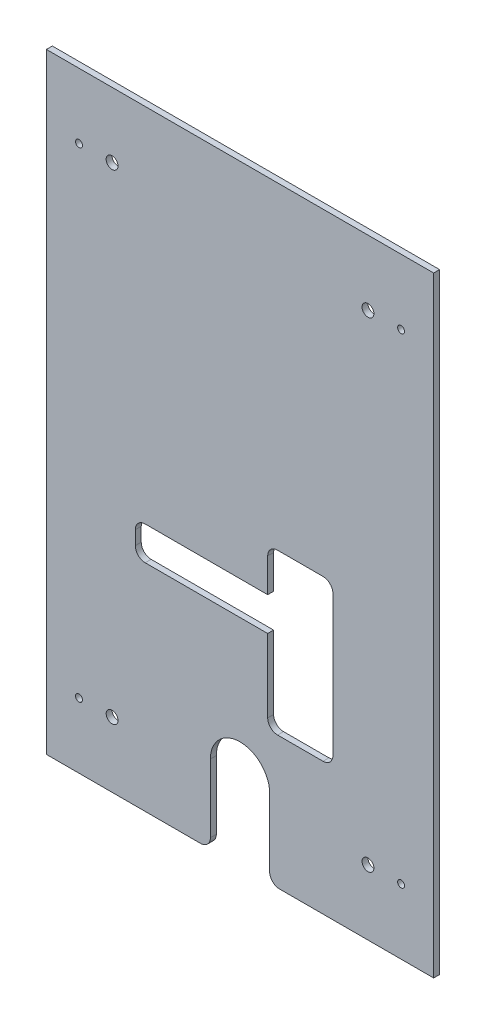
from build123d import *

# Parameters (mm, degrees)
ESQUISSE1_W             = 196
ESQUISSE1_H             = 309
ESQUISSE1_R             = 1.75
ESQUISSE1_R_2           = 3
BOSS_EXTRU_1_DEPTH      = 3
ENL_V_MAT_EXTRU_1_REACH = 5
CONG_1_R                = 5
ENL_V_MAT_EXTRU_2_DEPTH = 4
CONG_2_R                = 5


with BuildPart() as part:
    # Esquisse1 → Boss.-Extru.1 (new body)
    with BuildSketch(Plane.XY):
        Rectangle(ESQUISSE1_W, ESQUISSE1_H)
        with Locations((-81.5, 121.5)):
            Circle(ESQUISSE1_R, mode=Mode.SUBTRACT)
        with Locations((81.5, 121.5)):
            Circle(ESQUISSE1_R, mode=Mode.SUBTRACT)
        with Locations((81.5, -121.5)):
            Circle(ESQUISSE1_R, mode=Mode.SUBTRACT)
        with Locations((-81.5, -121.5)):
            Circle(ESQUISSE1_R, mode=Mode.SUBTRACT)
        with Locations((64.75, 121.5)):
            Circle(ESQUISSE1_R_2, mode=Mode.SUBTRACT)
        with Locations((-64.75, 121.5)):
            Circle(ESQUISSE1_R_2, mode=Mode.SUBTRACT)
        with Locations((-64.75, -121.5)):
            Circle(ESQUISSE1_R_2, mode=Mode.SUBTRACT)
        with Locations((64.75, -121.5)):
            Circle(ESQUISSE1_R_2, mode=Mode.SUBTRACT)
    extrude(amount=BOSS_EXTRU_1_DEPTH)

    # Esquisse2 → Enlèv. mat.-Extru.1 (cut, up to next)
    with BuildSketch(Plane.XY.offset(3), mode=Mode.PRIVATE) as enl_v_mat_extru_1_sk1:
        with BuildLine():
            Line((-15, -154.5), (-15, -115))
            ThreePointArc((-15, -115), (0, -100), (15, -115))
            Line((15, -115), (15, -154.5))
            ThreePointArc((15, -154.5), (0, -169.5), (-15, -154.5))
        make_face()
    enl_v_mat_extru_1_tool1 = extrude(enl_v_mat_extru_1_sk1.sketch, amount=-ENL_V_MAT_EXTRU_1_REACH, mode=Mode.PRIVATE) & part.part
    add(enl_v_mat_extru_1_tool1.solids().sort_by_distance((0, -134.75, 3))[0], mode=Mode.SUBTRACT)

    # Congé1
    cong_1_edges = [part.edges().sort_by_distance(p)[0] for p in [
        (-15, -154.5, 1.5),
        (15, -154.5, 1.5),
    ]]
    fillet(cong_1_edges, radius=CONG_1_R)

    # Esquisse3 → Enlèv. mat.-Extru.2 (cut, through all)
    with BuildSketch(Plane.XY.offset(3)):
        Polygon((-53, -28.5), (14, -28.5), (14, -6.5), (47, -6.5), (47, -87.5), (14, -87.5), (14, -45.5), (-53, -45.5), align=None)
    extrude(amount=-ENL_V_MAT_EXTRU_2_DEPTH, mode=Mode.SUBTRACT)

    # Congé2
    cong_2_edges = [part.edges().sort_by_distance(p)[0] for p in [
        (-53, -45.5, 1.5),
        (-53, -28.5, 1.5),
        (14, -6.5, 1.5),
        (47, -6.5, 1.5),
        (47, -87.5, 1.5),
        (14, -87.5, 1.5),
    ]]
    fillet(cong_2_edges, radius=CONG_2_R)


solid = part.part
